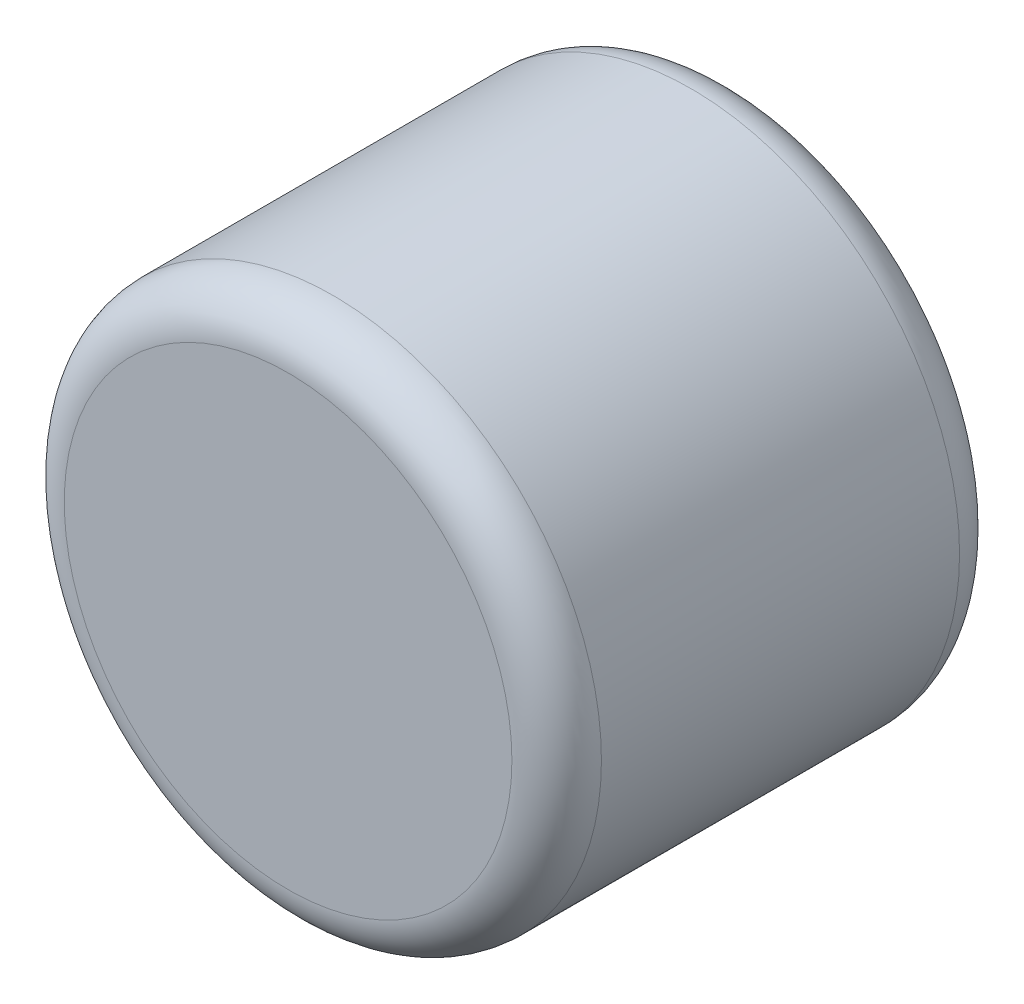
from build123d import *

# Parameters (mm, degrees)
SKETCH1_R           = 76.2
BOSS_EXTRUDE1_DEPTH = 127
FILLET1_R           = 12.7


with BuildPart() as part:
    # Sketch1 → Boss-Extrude1 (new body)
    with BuildSketch(Plane.XY):
        Circle(SKETCH1_R)
    extrude(amount=BOSS_EXTRUDE1_DEPTH)

    # Fillet1
    fillet1_edges = [part.edges().sort_by_distance(p)[0] for p in [
        (-76.2, 0, 0),
        (-76.2, 0, 127),
    ]]
    fillet(fillet1_edges, radius=FILLET1_R)


solid = part.part
